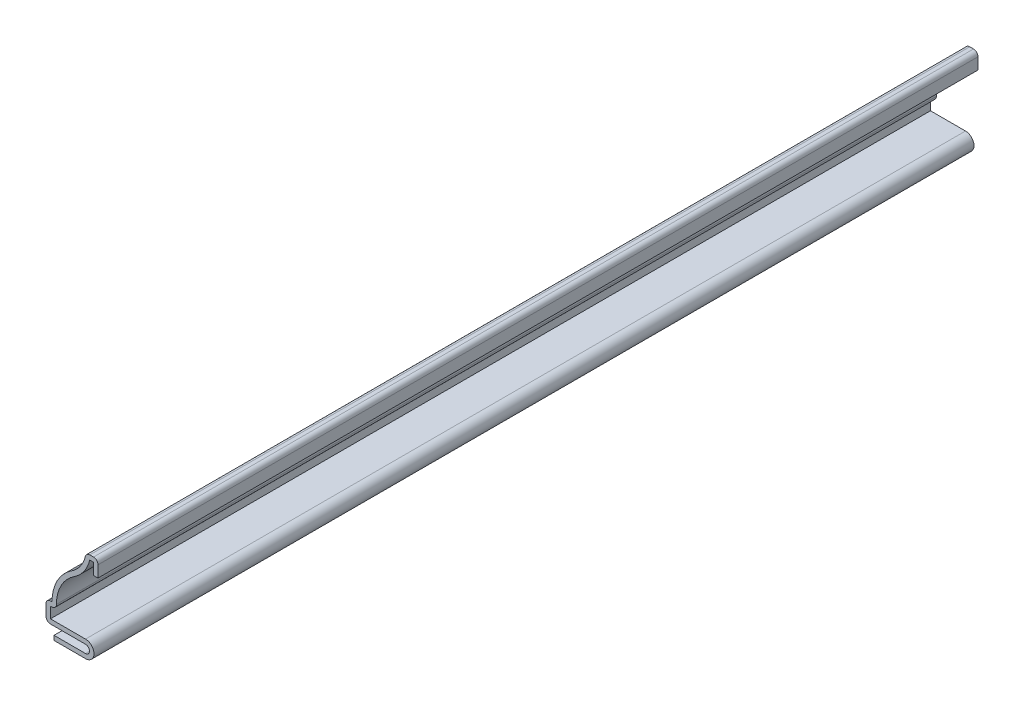
from build123d import *

# Parameters (mm, degrees)
BOSS_EXTRUDE1_DEPTH = 174.625
FILLET1_R           = 0.889


with BuildPart() as part:
    # Sketch1 → Boss-Extrude1 (new body)
    with BuildSketch(Plane.XY):
        with BuildLine():
            Line((-0.889, 15.08125), (-0.889, 17.36725))
            Line((-0.889, 17.36725), (-1.640744106, 17.36725))
            ThreePointArc((-1.640744106, 17.36725), (-2.756675468, 14.890646285), (-4.706872009, 12.99972))
            ThreePointArc((-4.706872009, 12.99972), (-7.503098361, 9.771250732), (-8.192782673, 5.55625))
            Line((-8.192782673, 5.55625), (-9.42975, 5.55625))
            Line((-9.42975, 5.55625), (-9.42975, 3.3655))
            Line((-9.42975, 3.3655), (-2.4765, 3.3655))
            ThreePointArc((-2.4765, 3.3655), (-0.79375, 1.68275), (-2.4765, 0))
            Line((-2.4765, 0), (-8.73125, 0))
            Line((-8.73125, 0), (-8.73125, 0.889))
            Line((-8.73125, 0.889), (-2.4765, 0.889))
            ThreePointArc((-2.4765, 0.889), (-1.68275, 1.68275), (-2.4765, 2.4765))
            Line((-2.4765, 2.4765), (-10.31875, 2.4765))
            Line((-10.31875, 2.4765), (-10.31875, 6.44525))
            Line((-10.31875, 6.44525), (-9.132334267, 6.44525))
            ThreePointArc((-9.132334267, 6.44525), (-8.085204479, 10.59121468), (-5.194977502, 13.742736842))
            ThreePointArc((-5.194977502, 13.742736842), (-3.292786478, 15.690706026), (-2.38125, 18.25625))
            Line((-2.38125, 18.25625), (0, 18.25625))
            Line((0, 18.25625), (0, 15.08125))
            Line((0, 15.08125), (-0.889, 15.08125))
        make_face()
    extrude(amount=-BOSS_EXTRUDE1_DEPTH)

    # Fillet1
    fillet1_edges = [part.edges().sort_by_distance(p)[0] for p in [
        (-8.192782673, 5.55625, -87.3125),
        (-10.31875, 2.4765, -87.3125),
        (-10.31875, 6.44525, -87.3125),
        (-2.38125, 18.25625, -87.3125),
        (0, 18.25625, -87.3125),
    ]]
    fillet(fillet1_edges, radius=FILLET1_R)


solid = part.part
